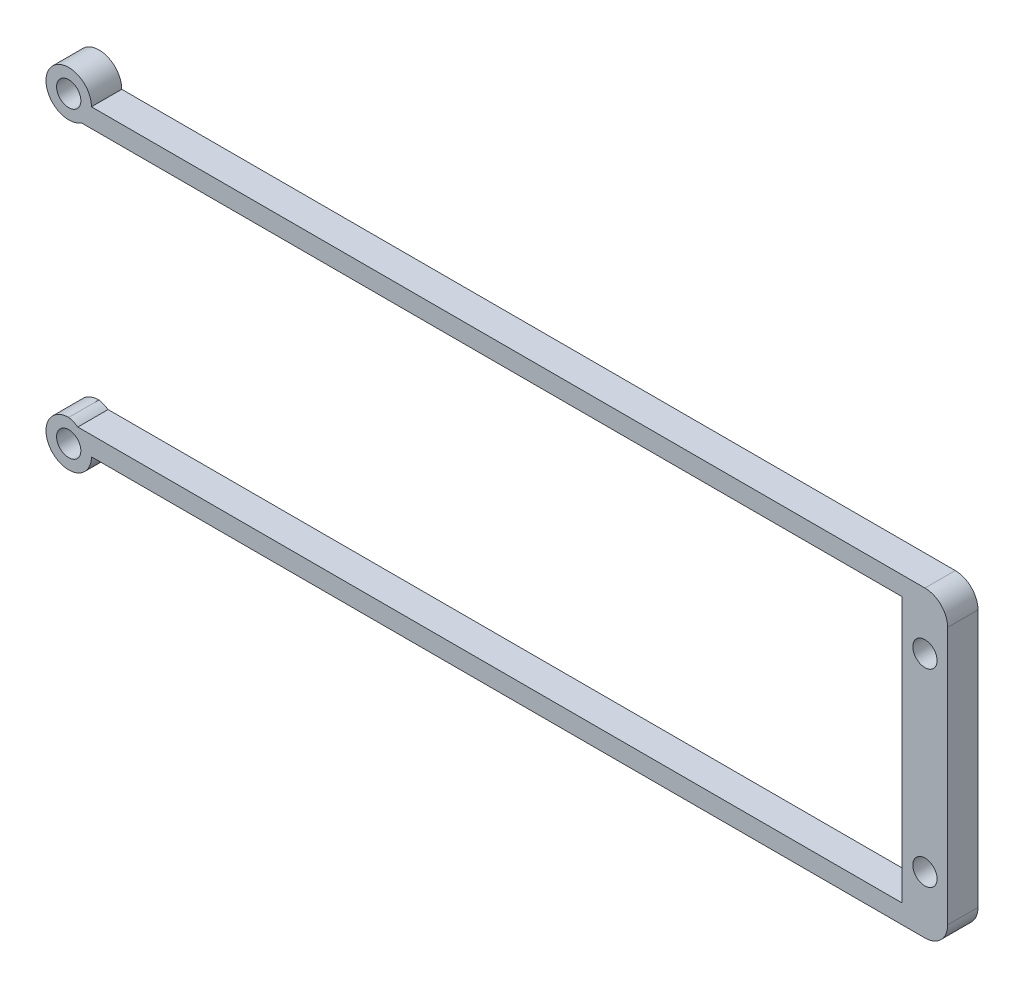
from build123d import *

# Parameters (mm, degrees)
SKETCH1_R           = 1.6
BOSS_EXTRUDE1_DEPTH = 4
SKETCH2_R           = 1.6
BOSS_EXTRUDE2_DEPTH = 4
SKETCH3_R           = 1.6
CUT_EXTRUDE1_DEPTH  = 4
SKETCH4_W           = 1
SKETCH4_H           = 46
BOSS_EXTRUDE4_DEPTH = 4
SKETCH6_R           = 1.6
SKETCH6_W           = 1
SKETCH6_H           = 34
CUT_EXTRUDE2_DEPTH  = 4
CUT_EXTRUDE4_DEPTH  = 4
FILLET2_R           = 3
CUT_EXTRUDE5_DEPTH  = 10
FILLET3_R           = 3


with BuildPart() as part:
    # Sketch1 → Boss-Extrude1 (new body)
    with BuildSketch(Plane.XY):
        with BuildLine():
            Line((0, 34), (106, 34))
            Line((106, 34), (106, 0))
            Line((106, 0), (0, 0))
            Line((0, 0), (-3, 0))
            ThreePointArc((-3, 0), (-6, -3), (-3, -6))
            Line((-3, -6), (112, -6))
            Line((112, -6), (112, 0))
            Line((112, 0), (112, 40))
            Line((112, 40), (-3, 40))
            ThreePointArc((-3, 40), (-6, 37), (-3, 34))
            Line((-3, 34), (0, 34))
        make_face()
        with Locations((-3, 37)):
            Circle(SKETCH1_R, mode=Mode.SUBTRACT)
        with Locations((-3, -3)):
            Circle(SKETCH1_R, mode=Mode.SUBTRACT)
        with Locations((109, 29.25)):
            Circle(SKETCH1_R, mode=Mode.SUBTRACT)
        with Locations((109, 4.75)):
            Circle(SKETCH1_R, mode=Mode.SUBTRACT)
    extrude(amount=BOSS_EXTRUDE1_DEPTH)

    # Sketch2 → Boss-Extrude2 (add)
    with BuildSketch(Plane.XY.offset(4)):
        with Locations((109, 4.75)):
            Circle(SKETCH2_R)
        with Locations((109, 29.25)):
            Circle(SKETCH2_R)
    extrude(amount=-BOSS_EXTRUDE2_DEPTH)

    # Sketch3 → Cut-Extrude1 (cut)
    with BuildSketch(Plane.XY.offset(4)):
        with Locations((109, 29.5)):
            Circle(SKETCH3_R)
        with Locations((109, 4.5)):
            Circle(SKETCH3_R)
    extrude(amount=-CUT_EXTRUDE1_DEPTH, mode=Mode.SUBTRACT)

    # Sketch4 → Boss-Extrude4 (add)
    with BuildSketch(Plane.XY.offset(4)):
        with Locations((112.5, 17)):
            Rectangle(SKETCH4_W, SKETCH4_H)
        with BuildLine():
            ThreePointArc((109.5, 27.980131585), (108.4, 29.5), (109.5, 31.019868415))
            ThreePointArc((109.5, 31.019868415), (107.4, 29.5), (109.5, 27.980131585))
        make_face()
        with BuildLine():
            ThreePointArc((109.566346567, 3.003587101), (108.401525498, 4.473847256), (109.433653433, 6.040111912))
            ThreePointArc((109.433653433, 6.040111912), (107.401525498, 4.430148243), (109.566346567, 3.003587101))
        make_face()
    extrude(amount=-BOSS_EXTRUDE4_DEPTH)

    # Sketch6 → Cut-Extrude2 (cut)
    with BuildSketch(Plane.XY.offset(4)):
        with Locations((110, 4.543699012)):
            Circle(SKETCH6_R)
        with Locations((110, 29.5)):
            Circle(SKETCH6_R)
        with Locations((106.5, 17)):
            Rectangle(SKETCH6_W, SKETCH6_H)
    extrude(amount=-CUT_EXTRUDE2_DEPTH, mode=Mode.SUBTRACT)

    # Sketch7 → Cut-Extrude4 (cut)
    with BuildSketch(Plane.XY.offset(4)):
        with BuildLine():
            Line((52, 0), (-3, 0))
            ThreePointArc((-3, 0), (-2.373132959, -0.184325643), (-1.801042119, -0.5))
            Line((-1.801042119, -0.5), (52, -0.5))
            Line((52, -0.5), (107, -0.5))
            Line((107, -0.5), (107, 0))
            Line((107, 0), (52, 0))
        make_face()
        with BuildLine():
            Line((52, 34.5), (-1.341687605, 34.5))
            ThreePointArc((-1.341687605, 34.5), (-2.133974596, 34.127718677), (-3, 34))
            Line((-3, 34), (52, 34))
            Line((52, 34), (107, 34))
            Line((107, 34), (107, 34.5))
            Line((107, 34.5), (52, 34.5))
        make_face()
    extrude(amount=-CUT_EXTRUDE4_DEPTH, mode=Mode.SUBTRACT)

    # Fillet2
    fillet2_edges = [part.edges().sort_by_distance(p)[0] for p in [
        (113, -6, 2),
        (113, 40, 2),
    ]]
    fillet(fillet2_edges, radius=FILLET2_R)

    # Sketch8 → Cut-Extrude5 (cut)
    with BuildSketch(Plane.XY.offset(4)):
        with BuildLine():
            Line((0, 37), (113, 37))
            Line((113, 37), (119.400968333, 46.55128084))
            Line((119.400968333, 46.55128084), (-5.470878247, 48.639937772))
            Line((-5.470878247, 48.639937772), (-3, 40))
            ThreePointArc((-3, 40), (-0.878679656, 39.121320344), (0, 37))
        make_face()
        with BuildLine():
            Line((0, -3), (113, -3))
            Line((113, -3), (122.38476395, -22.523587699))
            Line((122.38476395, -22.523587699), (1.093472111, -19.390602301))
            Line((1.093472111, -19.390602301), (-3, -6))
            ThreePointArc((-3, -6), (-0.878679656, -5.121320344), (0, -3))
        make_face()
    extrude(amount=-CUT_EXTRUDE5_DEPTH, mode=Mode.SUBTRACT)

    # Fillet3
    fillet3_edges = [part.edges().sort_by_distance(p)[0] for p in [
        (113, -3, 2),
        (113, 37, 2),
    ]]
    fillet(fillet3_edges, radius=FILLET3_R)


solid = part.part
